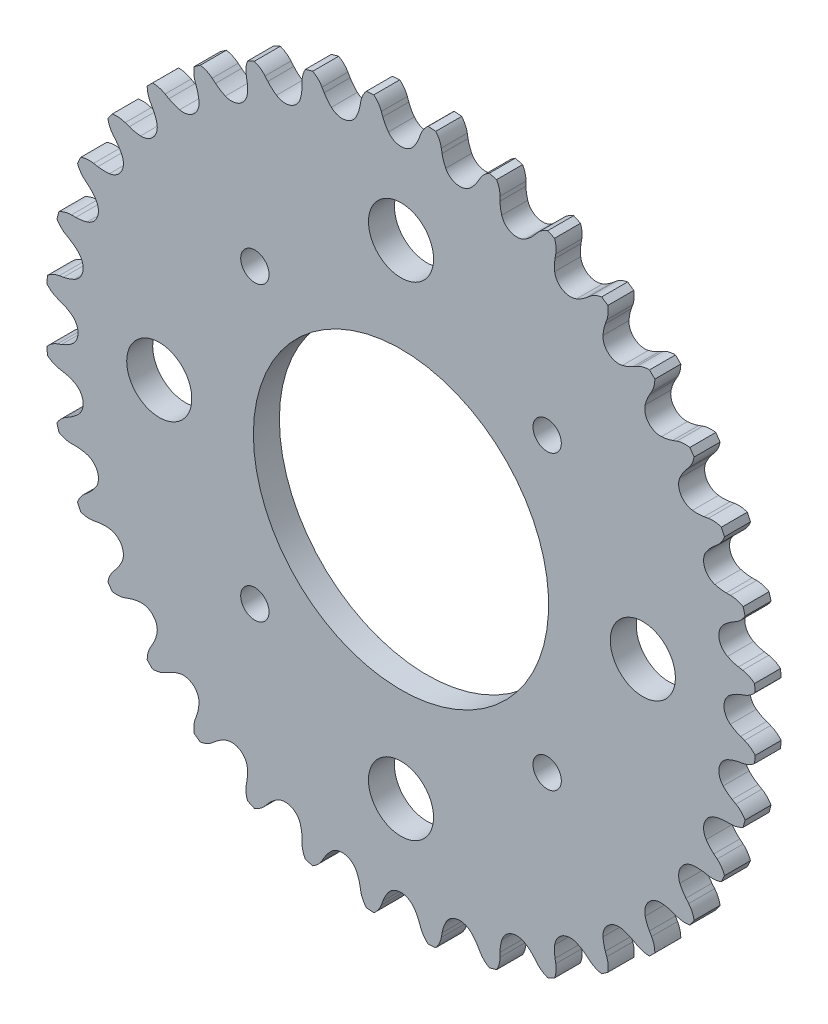
from build123d import *

# Parameters (mm, degrees)
TOOTH_CUT_NUMBER_OF_TEETH_36_DEPTH = 55.034537337
TOOTH_PATTERN_36_36_COUNT          = 36
SKETCH1_R                          = 15.875
SKETCH1_R_2                        = 3.5
SKETCH1_R_3                        = 1.524
CUT_EXTRUDE1_DEPTH                 = 54.930136686


with BuildPart() as part:
    # Sprocket-BaseSketch → 25 _04C_ ANSI _ISO_ Chain Number_ 2.868i (revolve)
    with BuildSketch(Plane(origin=(0, 0, 0), x_dir=(0, 0, -1), z_dir=(1, 0, 0))):
        Polygon((1.397, 0), (1.397, 35.020416061), (1.397, 38.195416061), (0.60325, 38.195416061), (-0.60325, 38.195416061), (-1.397, 38.195416061), (-1.397, 35.020416061), (-1.397, 0), align=None)
    revolve(axis=Axis((0, 0, -5.588), (0, 0, 1)))

    # Tooth-Sketch → Tooth-Cut_ Number of teeth_ 36 (cut, symmetric)
    with BuildSketch(Plane.XY):
        with BuildLine():
            Line((1.95260897, 36.506681097), (2.113680484, 36.943937247))
            ThreePointArc((2.113680484, 36.943937247), (3.086471, 38.204095605), (4.60520885, 38.681333297))
            ThreePointArc((4.60520885, 38.681333297), (0, 38.954505442), (-4.60520885, 38.681333297))
            ThreePointArc((-4.60520885, 38.681333297), (-3.086471, 38.204095605), (-2.113680484, 36.943937247))
            Line((-2.113680484, 36.943937247), (-1.95260897, 36.506681097))
            ThreePointArc((-1.95260897, 36.506681097), (-1.696264974, 35.939821607), (-1.361487812, 35.415449434))
            ThreePointArc((-1.361487812, 35.415449434), (0, 34.731684555), (1.361487812, 35.415449434))
            ThreePointArc((1.361487812, 35.415449434), (1.696264974, 35.939821607), (1.95260897, 36.506681097))
        make_face()
    tooth_cut_number_of_teeth_36 = extrude(amount=TOOTH_CUT_NUMBER_OF_TEETH_36_DEPTH, both=True, mode=Mode.SUBTRACT)

    # Tooth Pattern_ 36 _ 36: Tooth-Cut_ Number of teeth_ 36 ×36 about axis
    tooth_pattern_36_36_axis = Axis((0, 0, -88.99), (0, 0, 1))
    for i in range(1, TOOTH_PATTERN_36_36_COUNT):
        add(tooth_cut_number_of_teeth_36.rotate(tooth_pattern_36_36_axis, i * 360 / TOOTH_PATTERN_36_36_COUNT), mode=Mode.SUBTRACT)

    # Sketch1 → Cut-Extrude1 (cut, through all)
    with BuildSketch(Plane(origin=(0, 0, -1.397), x_dir=(-1, 0, 0), z_dir=(0, 0, -1))):
        Circle(SKETCH1_R)
        with Locations((-26.003100001, 0.000166268)):
            Circle(SKETCH1_R_2)
        with Locations((-15.715448212, 15.715448212)):
            Circle(SKETCH1_R_3)
        with Locations((15.715448212, 15.715448212)):
            Circle(SKETCH1_R_3)
        with Locations((25.996899993, -0.00061715)):
            Circle(SKETCH1_R_2)
        with Locations((15.715448212, -15.715448212)):
            Circle(SKETCH1_R_3)
        with Locations((0.000617243, 26.003099995)):
            Circle(SKETCH1_R_2)
        with Locations((-15.715448212, -15.715448212)):
            Circle(SKETCH1_R_3)
        with Locations((-0.000166275, -26.003550977)):
            Circle(SKETCH1_R_2)
    extrude(amount=-CUT_EXTRUDE1_DEPTH, mode=Mode.SUBTRACT)


solid = part.part
